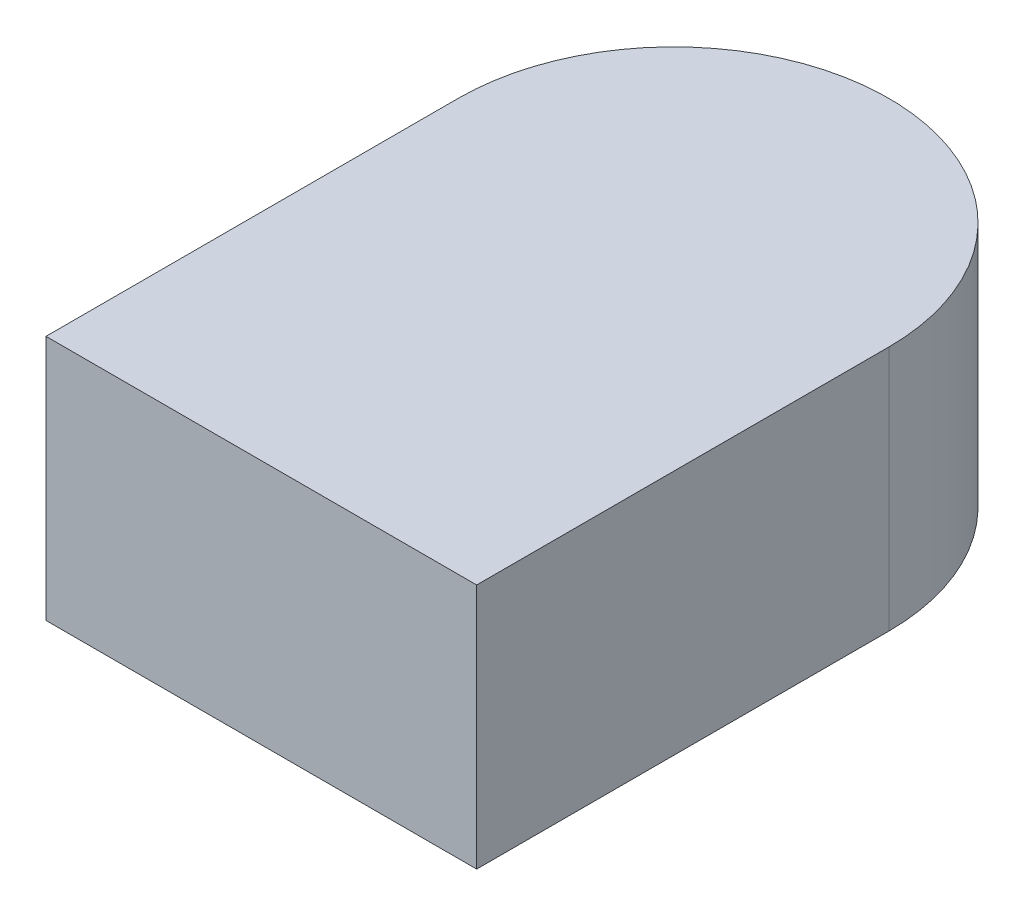
from build123d import *

# Parameters (mm, degrees)
BOSS_EXTRUDE1_DEPTH = 0.2


with BuildPart() as part:
    # Sketch1 → Boss-Extrude1 (new body)
    with BuildSketch(Plane(origin=(0, 0, 0), x_dir=(1, 0, 0), z_dir=(0, 1, 0))):
        with BuildLine():
            Line((-0.175, 0.1675), (-0.175, -0.1675))
            Line((-0.175, -0.1675), (0.175, -0.1675))
            Line((0.175, -0.1675), (0.175, 0.1675))
            ThreePointArc((0.175, 0.1675), (0, 0.3425), (-0.175, 0.1675))
        make_face()
    extrude(amount=BOSS_EXTRUDE1_DEPTH)


solid = part.part
